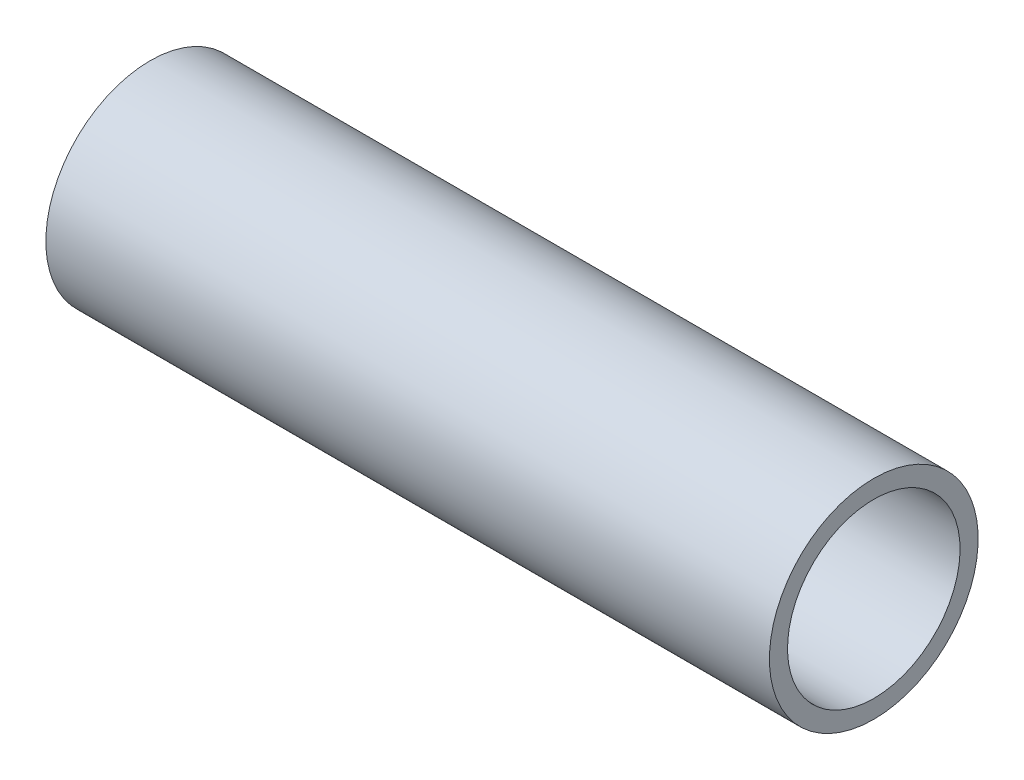
from build123d import *

# Parameters (mm, degrees)
SKETCH4_R   = 9.525
SKETCH4_R_2 = 7.874


with BuildPart() as part:
    # Sweep1: sweep along a path in Sketch3
    with BuildLine(Plane.XY) as sweep1_path:
        Line((66.04, 0), (0, 0))
    # Sketch4 → Sweep1 (sweep)
    with BuildSketch(Plane.ZY.offset(-66.04)):
        Circle(SKETCH4_R)
        Circle(SKETCH4_R_2, mode=Mode.SUBTRACT)
    sweep(path=sweep1_path.line)


solid = part.part
